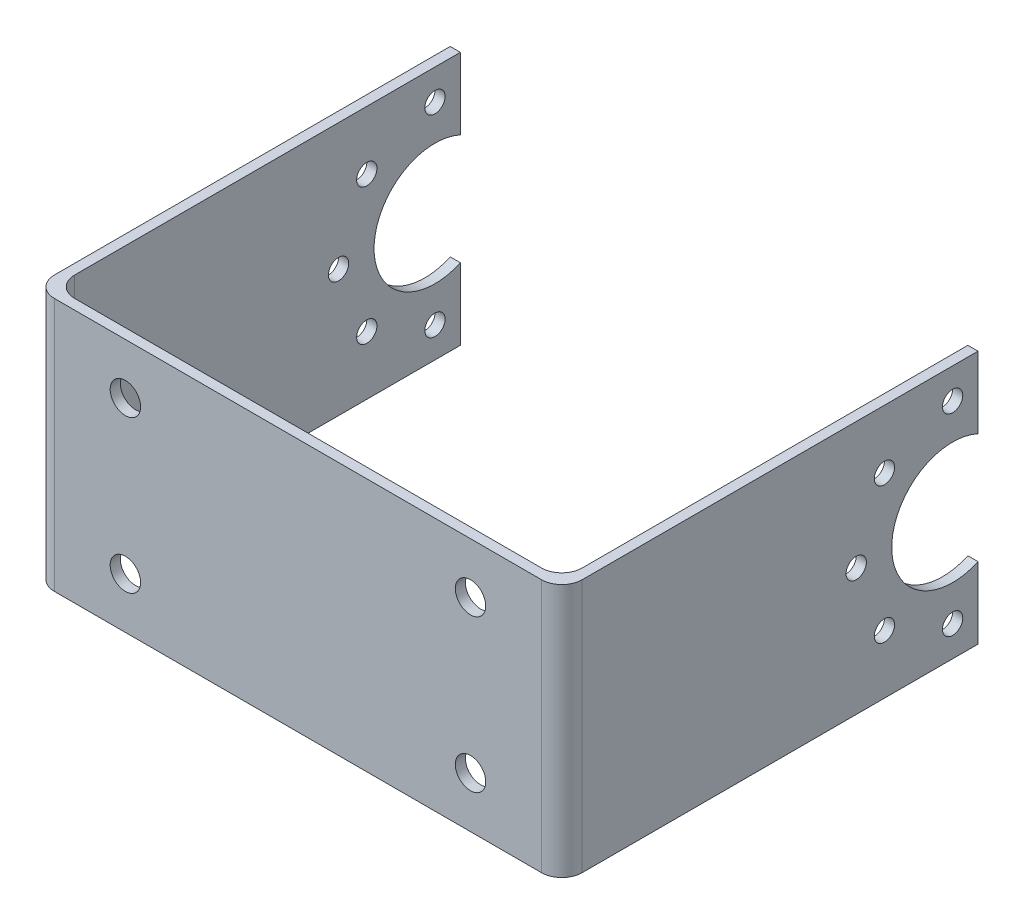
from build123d import *

# Parameters (mm, degrees)
BOSS_EXTRUDE1_DEPTH = 25
SKETCH2_R           = 1
SKETCH2_R_2         = 6
CUT_EXTRUDE1_DEPTH  = 53
FILLET2_R           = 2
SKETCH3_R           = 1.5
CUT_EXTRUDE2_DEPTH  = 42


with BuildPart() as part:
    # Sketch1 → Boss-Extrude1 (new body)
    with BuildSketch(Plane(origin=(0, 0, 0), x_dir=(1, 0, 0), z_dir=(0, 1, 0))):
        Polygon((-21.5, 0.5), (28.5, 0.5), (28.5, 40.5), (29.5, 40.5), (29.5, 0.5), (29.5, -0.5), (-22.5, -0.5), (-22.5, 0.5), (-22.5, 40.5), (-21.5, 40.5), align=None)
    extrude(amount=BOSS_EXTRUDE1_DEPTH)

    # Sketch2 → Cut-Extrude1 (cut, through all)
    with BuildSketch(Plane(origin=(29.5, 0, 0), x_dir=(0, 0, -1), z_dir=(1, 0, 0))):
        with Locations((28.5, 12.5)):
            Circle(SKETCH2_R)
        with Locations((38, 12.5)):
            Circle(SKETCH2_R_2)
        with Locations((31.282485579, 19.217514421)):
            Circle(SKETCH2_R)
        with Locations((38, 22)):
            Circle(SKETCH2_R)
        with Locations((38, 3)):
            Circle(SKETCH2_R)
        with Locations((31.282485579, 5.782485579)):
            Circle(SKETCH2_R)
    extrude(amount=-CUT_EXTRUDE1_DEPTH, mode=Mode.SUBTRACT)

    # Fillet2
    fillet2_edges = [part.edges().sort_by_distance(p)[0] for p in [
        (29.5, 12.5, 0.5),
        (-22.5, 12.5, 0.5),
        (-21.5, 12.5, -0.5),
        (28.5, 12.5, -0.5),
    ]]
    fillet(fillet2_edges, radius=FILLET2_R)

    # Sketch3 → Cut-Extrude2 (cut, through all)
    with BuildSketch(Plane.XY.offset(0.5)):
        with Locations((-13.5, 20)):
            Circle(SKETCH3_R)
        with Locations((20.5, 20)):
            Circle(SKETCH3_R)
        with Locations((-13.5, 5)):
            Circle(SKETCH3_R)
        with Locations((20.5, 5)):
            Circle(SKETCH3_R)
    extrude(amount=-CUT_EXTRUDE2_DEPTH, mode=Mode.SUBTRACT)


solid = part.part
